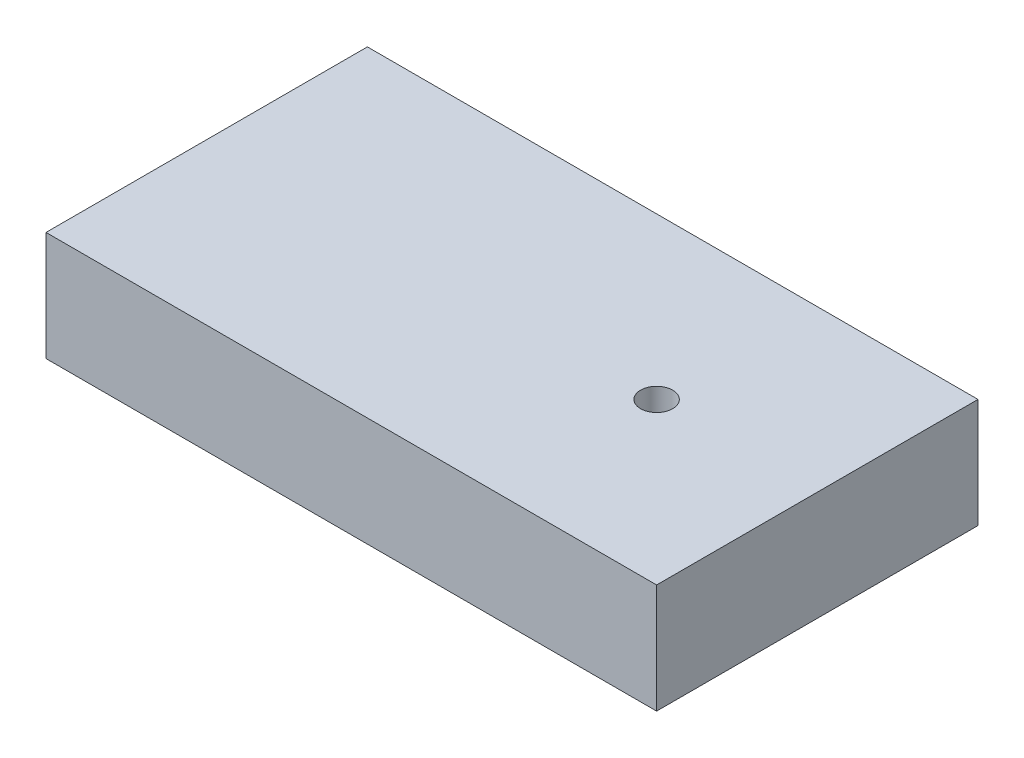
from build123d import *

# Parameters (mm, degrees)
SKETCH1_W           = 48.26
SKETCH1_H           = 25.4
BOSS_EXTRUDE1_DEPTH = 8.636
SKETCH2_R           = 1.27
CUT_EXTRUDE1_DEPTH  = 9.636


with BuildPart() as part:
    # Sketch1 → Boss-Extrude1 (new body)
    with BuildSketch(Plane(origin=(0, 0, 0), x_dir=(1, 0, 0), z_dir=(0, 1, 0))):
        with Locations((24.13, 12.7)):
            Rectangle(SKETCH1_W, SKETCH1_H)
    extrude(amount=BOSS_EXTRUDE1_DEPTH)

    # Sketch2 → Cut-Extrude1 (cut, through all)
    with BuildSketch(Plane(origin=(0, 8.636, 0), x_dir=(1, 0, 0), z_dir=(0, 1, 0))):
        with Locations((35.56, 12.7)):
            Circle(SKETCH2_R)
    extrude(amount=-CUT_EXTRUDE1_DEPTH, mode=Mode.SUBTRACT)


solid = part.part
